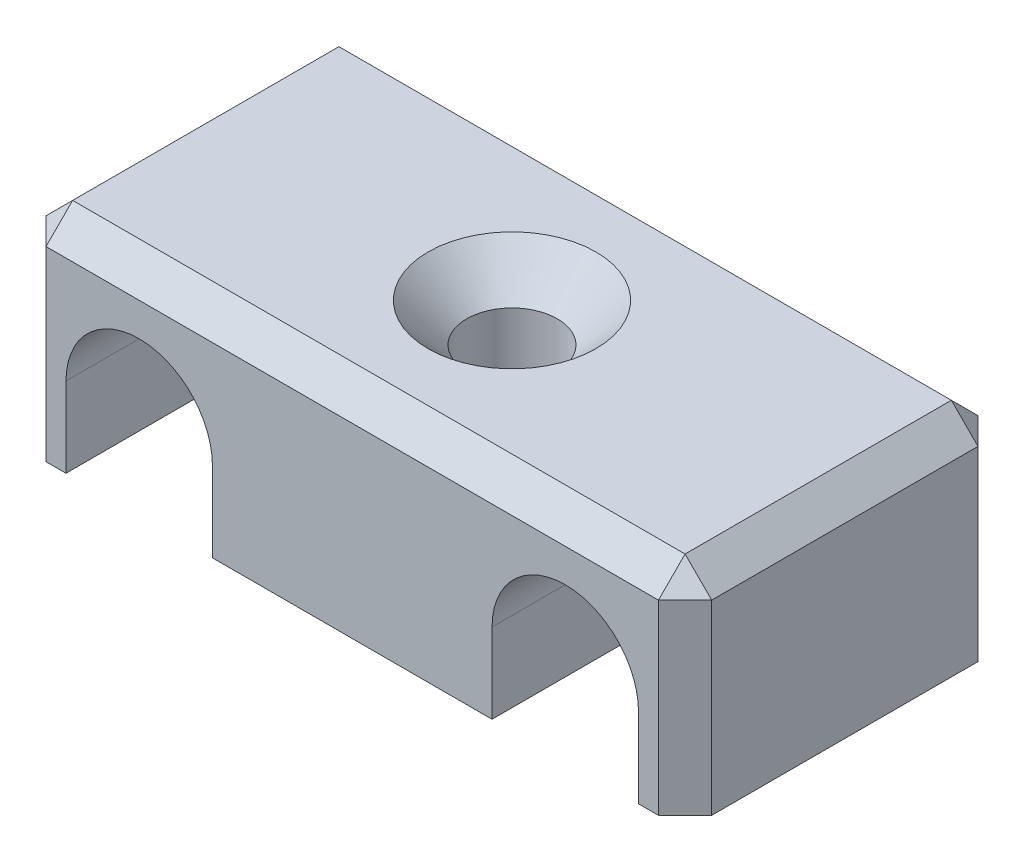
from build123d import *

# Parameters (mm, degrees)
ESQUISSE1_W                                    = 25
ESQUISSE1_H                                    = 8
BOSS_EXTRU_1_DEPTH                             = 12
FRAISAGE_POUR_VIS_T_TE_FRAIS_E_M31_D           = 3.4
FRAISAGE_POUR_VIS_T_TE_FRAIS_E_M31_CSINK_D     = 6.3
FRAISAGE_POUR_VIS_T_TE_FRAIS_E_M31_CSINK_ANGLE = 90
ENL_V_MAT_EXTRU_1_DEPTH                        = 13
CHANFREIN1_SIZE                                = 1


with BuildPart() as part:
    # Esquisse1 → Boss.-Extru.1 (new body)
    with BuildSketch(Plane.XY):
        Rectangle(ESQUISSE1_W, ESQUISSE1_H)
    extrude(amount=BOSS_EXTRU_1_DEPTH)

    # Fraisage pour vis à tête fraisée M31 (through all)
    with Locations(Plane(origin=(0, 4, 0), x_dir=(1, 0, 0), z_dir=(0, 1, 0))):
        with Locations((0, -6)):
            CounterSinkHole(FRAISAGE_POUR_VIS_T_TE_FRAIS_E_M31_D / 2, FRAISAGE_POUR_VIS_T_TE_FRAIS_E_M31_CSINK_D / 2, counter_sink_angle=FRAISAGE_POUR_VIS_T_TE_FRAIS_E_M31_CSINK_ANGLE)

    # Esquisse4 → Enlèv. mat.-Extru.1 (cut, through all)
    with BuildSketch(Plane.XY.offset(12)):
        with BuildLine():
            Line((-5.25, -1), (-5.25, -4))
            Line((-5.25, -4), (-10.75, -4))
            Line((-10.75, -4), (-10.75, -1))
            ThreePointArc((-10.75, -1), (-8, 1.75), (-5.25, -1))
        make_face()
        with BuildLine():
            Line((5.25, -1), (5.25, -4))
            Line((5.25, -4), (10.75, -4))
            Line((10.75, -4), (10.75, -1))
            ThreePointArc((10.75, -1), (8, 1.75), (5.25, -1))
        make_face()
    extrude(amount=-ENL_V_MAT_EXTRU_1_DEPTH, mode=Mode.SUBTRACT)

    # Chanfrein1
    chanfrein1_edges = [part.edges().sort_by_distance(p)[0] for p in [
        (-12.5, 0, 12),
        (12.5, 0, 12),
        (-12.5, 0, 0),
        (0, 4, 0),
        (12.5, 0, 0),
        (-12.5, 4, 6),
        (12.5, 4, 6),
        (0, 4, 12),
    ]]
    chamfer(chanfrein1_edges, length=CHANFREIN1_SIZE)


solid = part.part
